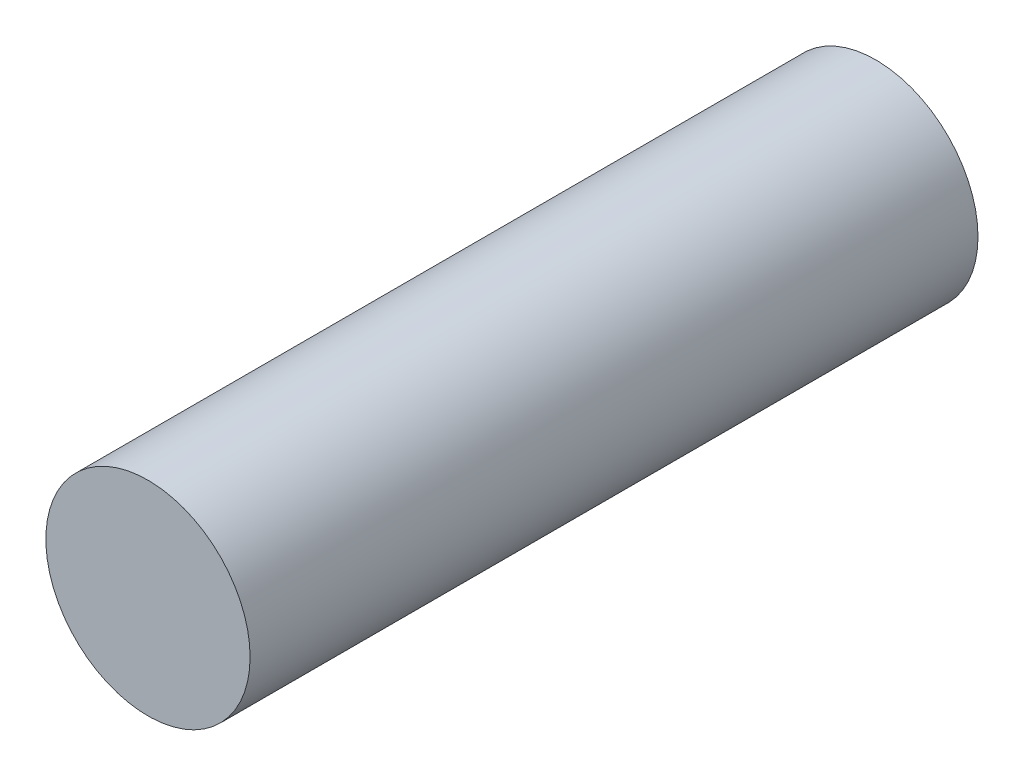
from build123d import *

# Parameters (mm, degrees)
SKETCH2_R           = 1.375
BOSS_EXTRUDE1_DEPTH = 9.8


with BuildPart() as part:
    # Sketch2 → Boss-Extrude1 (new body)
    with BuildSketch(Plane.XY):
        Circle(SKETCH2_R)
    extrude(amount=BOSS_EXTRUDE1_DEPTH)


solid = part.part
